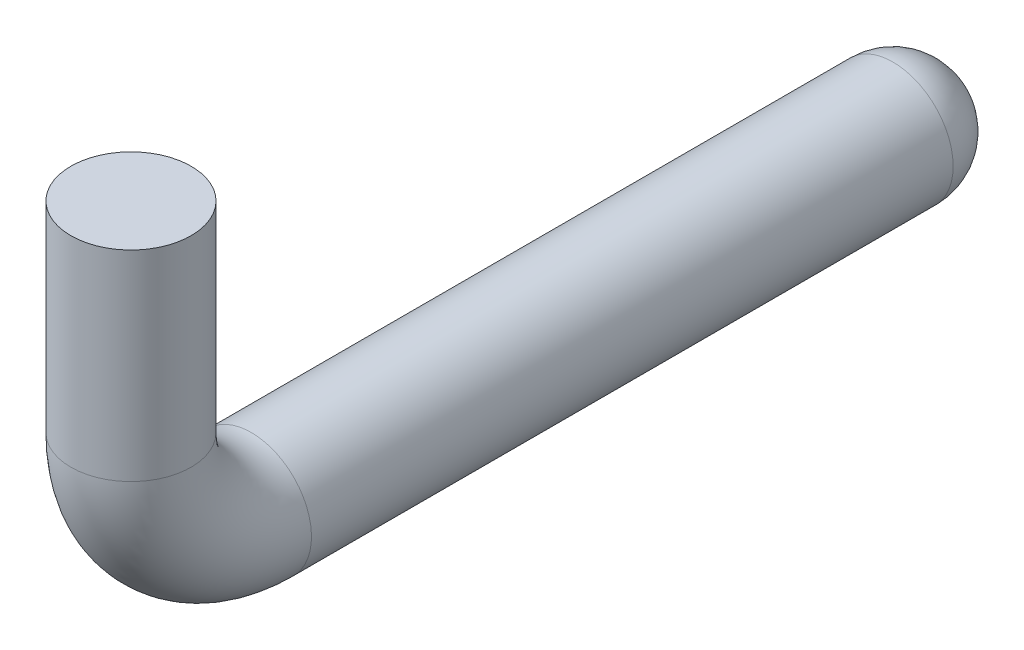
from build123d import *

# Parameters (mm, degrees)
CROQUIS2_R          = 0.075
C_PULA1_FACE_RADIUS = 0.075
C_PULA1_HEIGHT      = 0.075


with BuildPart() as part:
    # Barrer1: sweep along a path in Croquis1
    with BuildLine(Plane(origin=(0, 0, 0), x_dir=(0, 0, -1), z_dir=(1, 0, 0))) as barrer1_path:
        Line((0, 0), (0, -0.25))
        ThreePointArc((0, -0.25), (0.043933983, -0.356066017), (0.15, -0.4))
        Line((0.15, -0.4), (0.95, -0.4))
    # Croquis2 → Barrer1 (sweep)
    with BuildSketch(Plane(origin=(0, 0, 0), x_dir=(1, 0, 0), z_dir=(0, 1, 0))):
        Circle(CROQUIS2_R)
    sweep(path=barrer1_path.line)

    # C_pula1: a dome of height H over a round flat face of radius A is a cap of a sphere of radius (A * A + H * H) / (2 * H)
    c_pula1_r = (C_PULA1_FACE_RADIUS * C_PULA1_FACE_RADIUS + C_PULA1_HEIGHT * C_PULA1_HEIGHT) / (2 * C_PULA1_HEIGHT)
    c_pula1_base = Plane((0, -0.4, -0.95), z_dir=(0, 0, -1))
    with Locations(c_pula1_base.offset(C_PULA1_HEIGHT - c_pula1_r)):
        c_pula1_ball = Sphere(c_pula1_r, mode=Mode.PRIVATE)
    add(split(c_pula1_ball, bisect_by=c_pula1_base, keep=Keep.TOP, mode=Mode.PRIVATE))


solid = part.part
